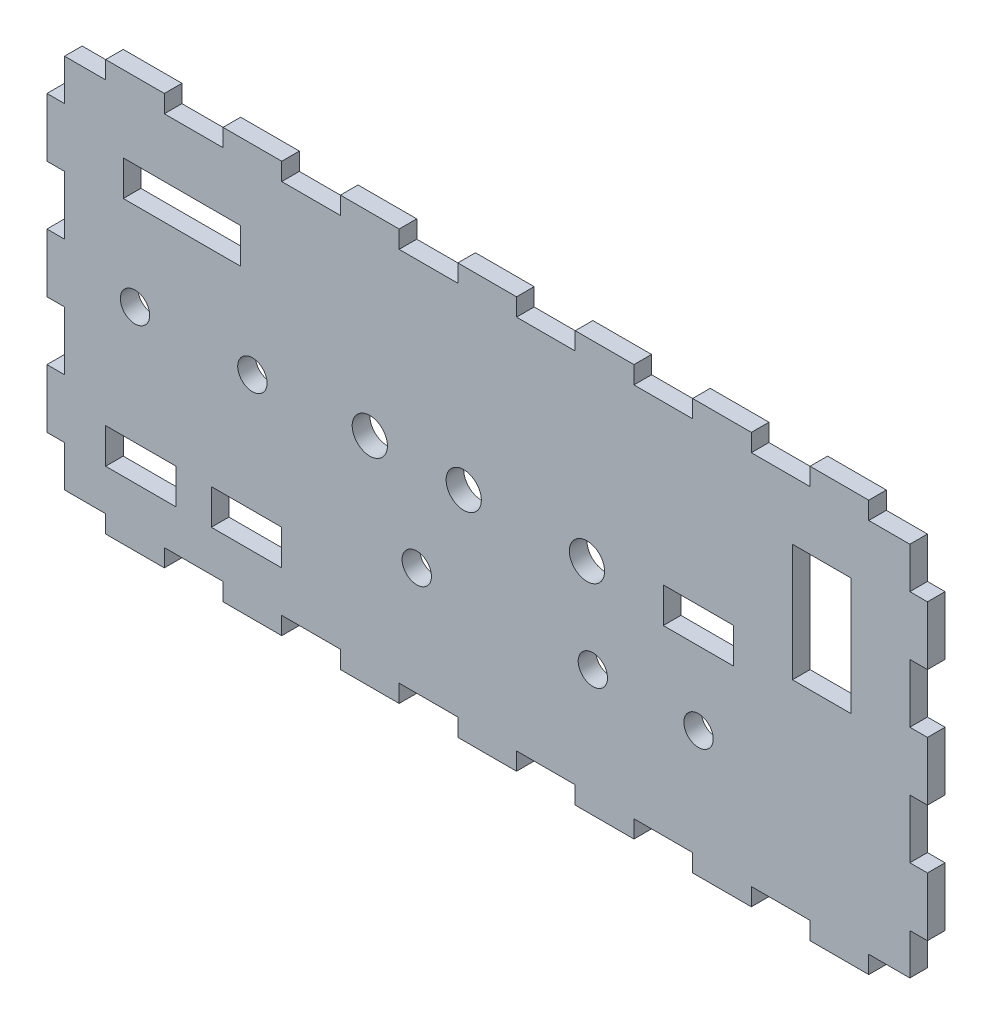
from build123d import *

# Parameters (mm, degrees)
SKETCH1_W               = 150
SKETCH1_H               = 70
BOSS_EXTRUDE1_DEPTH     = 3
SKETCH2_W               = 10
SKETCH2_H               = 3
CUT_EXTRUDE1_DEPTH      = 3
LPATTERN3_COUNT         = 8
LPATTERN3_PITCH         = 20
MIRROR1_COPY_1_SKETCH_W = 10
MIRROR1_COPY_1_SKETCH_H = 3
MIRROR1_COPY_1_DEPTH    = 3
MIRROR1_COPY_2_SKETCH_W = 10
MIRROR1_COPY_2_SKETCH_H = 3
MIRROR1_COPY_2_DEPTH    = 3
MIRROR1_COPY_3_SKETCH_W = 10
MIRROR1_COPY_3_SKETCH_H = 3
MIRROR1_COPY_3_DEPTH    = 3
MIRROR1_COPY_4_SKETCH_W = 10
MIRROR1_COPY_4_SKETCH_H = 3
MIRROR1_COPY_4_DEPTH    = 3
MIRROR1_COPY_5_SKETCH_W = 10
MIRROR1_COPY_5_SKETCH_H = 3
MIRROR1_COPY_5_DEPTH    = 3
MIRROR1_COPY_6_SKETCH_W = 10
MIRROR1_COPY_6_SKETCH_H = 3
MIRROR1_COPY_6_DEPTH    = 3
MIRROR1_COPY_7_SKETCH_W = 10
MIRROR1_COPY_7_SKETCH_H = 3
MIRROR1_COPY_7_DEPTH    = 3
SKETCH3_W               = 3
SKETCH3_H               = 10
CUT_EXTRUDE2_DEPTH      = 3
LPATTERN4_COUNT         = 4
LPATTERN4_PITCH         = 20
MIRROR2_COPY_1_SKETCH_W = 3
MIRROR2_COPY_1_SKETCH_H = 10
MIRROR2_COPY_1_DEPTH    = 3
MIRROR2_COPY_2_SKETCH_W = 3
MIRROR2_COPY_2_SKETCH_H = 10
MIRROR2_COPY_2_DEPTH    = 3
MIRROR2_COPY_3_SKETCH_W = 3
MIRROR2_COPY_3_SKETCH_H = 10
MIRROR2_COPY_3_DEPTH    = 3
SKETCH4_W               = 20
SKETCH4_H               = 6
CUT_EXTRUDE3_DEPTH      = 3
SKETCH5_R               = 2.5
CUT_EXTRUDE5_DEPTH      = 3
SKETCH6_W               = 12
SKETCH6_H               = 6
CUT_EXTRUDE6_DEPTH      = 3
SKETCH7_R               = 3
CUT_EXTRUDE7_DEPTH      = 3
SKETCH8_R               = 2.5
CUT_EXTRUDE8_DEPTH      = 3
SKETCH9_R               = 3
CUT_EXTRUDE9_DEPTH      = 3
SKETCH10_W              = 12
SKETCH10_H              = 6
CUT_EXTRUDE10_DEPTH     = 3
SKETCH11_R              = 2.5
CUT_EXTRUDE11_DEPTH     = 3
SKETCH12_W              = 10
SKETCH12_H              = 20
CUT_EXTRUDE12_DEPTH     = 3


with BuildPart() as part:
    # Sketch1 → Boss-Extrude1 (new body)
    with BuildSketch(Plane.XY):
        Rectangle(SKETCH1_W, SKETCH1_H)
    extrude(amount=BOSS_EXTRUDE1_DEPTH)

    # Sketch2 → Cut-Extrude1 (cut)
    with BuildSketch(Plane.XY.offset(3)):
        with Locations((-70, 33.5)):
            Rectangle(SKETCH2_W, SKETCH2_H)
    cut_extrude1 = extrude(amount=-CUT_EXTRUDE1_DEPTH, mode=Mode.SUBTRACT)

    # LPattern3: Cut-Extrude1 ×8
    with Locations(*[(i * LPATTERN3_PITCH, 0, 0) for i in range(1, LPATTERN3_COUNT)]):
        add(cut_extrude1, mode=Mode.SUBTRACT)

    # Mirror1: Cut-Extrude1 across plane
    add(cut_extrude1.mirror(Plane.ZX), mode=Mode.SUBTRACT)

    # Mirror1 copy 1 sketch → Mirror1 copy 1 (cut)
    with BuildSketch(Plane(origin=(20, 0, 3), x_dir=(1, 0, 0), z_dir=(0, 0, 1))):
        with Locations((-70, -33.5)):
            Rectangle(MIRROR1_COPY_1_SKETCH_W, MIRROR1_COPY_1_SKETCH_H)
    extrude(amount=-MIRROR1_COPY_1_DEPTH, mode=Mode.SUBTRACT)

    # Mirror1 copy 2 sketch → Mirror1 copy 2 (cut)
    with BuildSketch(Plane(origin=(40, 0, 3), x_dir=(1, 0, 0), z_dir=(0, 0, 1))):
        with Locations((-70, -33.5)):
            Rectangle(MIRROR1_COPY_2_SKETCH_W, MIRROR1_COPY_2_SKETCH_H)
    extrude(amount=-MIRROR1_COPY_2_DEPTH, mode=Mode.SUBTRACT)

    # Mirror1 copy 3 sketch → Mirror1 copy 3 (cut)
    with BuildSketch(Plane(origin=(60, 0, 3), x_dir=(1, 0, 0), z_dir=(0, 0, 1))):
        with Locations((-70, -33.5)):
            Rectangle(MIRROR1_COPY_3_SKETCH_W, MIRROR1_COPY_3_SKETCH_H)
    extrude(amount=-MIRROR1_COPY_3_DEPTH, mode=Mode.SUBTRACT)

    # Mirror1 copy 4 sketch → Mirror1 copy 4 (cut)
    with BuildSketch(Plane(origin=(80, 0, 3), x_dir=(1, 0, 0), z_dir=(0, 0, 1))):
        with Locations((-70, -33.5)):
            Rectangle(MIRROR1_COPY_4_SKETCH_W, MIRROR1_COPY_4_SKETCH_H)
    extrude(amount=-MIRROR1_COPY_4_DEPTH, mode=Mode.SUBTRACT)

    # Mirror1 copy 5 sketch → Mirror1 copy 5 (cut)
    with BuildSketch(Plane(origin=(100, 0, 3), x_dir=(1, 0, 0), z_dir=(0, 0, 1))):
        with Locations((-70, -33.5)):
            Rectangle(MIRROR1_COPY_5_SKETCH_W, MIRROR1_COPY_5_SKETCH_H)
    extrude(amount=-MIRROR1_COPY_5_DEPTH, mode=Mode.SUBTRACT)

    # Mirror1 copy 6 sketch → Mirror1 copy 6 (cut)
    with BuildSketch(Plane(origin=(120, 0, 3), x_dir=(1, 0, 0), z_dir=(0, 0, 1))):
        with Locations((-70, -33.5)):
            Rectangle(MIRROR1_COPY_6_SKETCH_W, MIRROR1_COPY_6_SKETCH_H)
    extrude(amount=-MIRROR1_COPY_6_DEPTH, mode=Mode.SUBTRACT)

    # Mirror1 copy 7 sketch → Mirror1 copy 7 (cut)
    with BuildSketch(Plane(origin=(140, 0, 3), x_dir=(1, 0, 0), z_dir=(0, 0, 1))):
        with Locations((-70, -33.5)):
            Rectangle(MIRROR1_COPY_7_SKETCH_W, MIRROR1_COPY_7_SKETCH_H)
    extrude(amount=-MIRROR1_COPY_7_DEPTH, mode=Mode.SUBTRACT)

    # Sketch3 → Cut-Extrude2 (cut)
    with BuildSketch(Plane.XY.offset(3)):
        with Locations((-73.5, 30)):
            Rectangle(SKETCH3_W, SKETCH3_H)
    cut_extrude2 = extrude(amount=-CUT_EXTRUDE2_DEPTH, mode=Mode.SUBTRACT)

    # LPattern4: Cut-Extrude2 ×4
    with Locations(*[(0, -i * LPATTERN4_PITCH, 0) for i in range(1, LPATTERN4_COUNT)]):
        add(cut_extrude2, mode=Mode.SUBTRACT)

    # Mirror2: Cut-Extrude2 across plane
    add(cut_extrude2.mirror(Plane(origin=(0, 0, 0), x_dir=(0, 0, 1), z_dir=(1, 0, 0))), mode=Mode.SUBTRACT)

    # Mirror2 copy 1 sketch → Mirror2 copy 1 (cut)
    with BuildSketch(Plane(origin=(0, -20, 3), x_dir=(-1, 0, 0), z_dir=(0, 0, 1))):
        with Locations((-73.5, -30)):
            Rectangle(MIRROR2_COPY_1_SKETCH_W, MIRROR2_COPY_1_SKETCH_H)
    extrude(amount=-MIRROR2_COPY_1_DEPTH, mode=Mode.SUBTRACT)

    # Mirror2 copy 2 sketch → Mirror2 copy 2 (cut)
    with BuildSketch(Plane(origin=(0, -40, 3), x_dir=(-1, 0, 0), z_dir=(0, 0, 1))):
        with Locations((-73.5, -30)):
            Rectangle(MIRROR2_COPY_2_SKETCH_W, MIRROR2_COPY_2_SKETCH_H)
    extrude(amount=-MIRROR2_COPY_2_DEPTH, mode=Mode.SUBTRACT)

    # Mirror2 copy 3 sketch → Mirror2 copy 3 (cut)
    with BuildSketch(Plane(origin=(0, -60, 3), x_dir=(-1, 0, 0), z_dir=(0, 0, 1))):
        with Locations((-73.5, -30)):
            Rectangle(MIRROR2_COPY_3_SKETCH_W, MIRROR2_COPY_3_SKETCH_H)
    extrude(amount=-MIRROR2_COPY_3_DEPTH, mode=Mode.SUBTRACT)

    # Sketch4 → Cut-Extrude3 (cut)
    with BuildSketch(Plane.XY.offset(3)):
        with Locations((-52, 19)):
            Rectangle(SKETCH4_W, SKETCH4_H)
    extrude(amount=-CUT_EXTRUDE3_DEPTH, mode=Mode.SUBTRACT)

    # Sketch5 → Cut-Extrude5 (cut)
    with BuildSketch(Plane.XY.offset(3)):
        with Locations((-60, 1)):
            Circle(SKETCH5_R)
        with Locations((-40, 1)):
            Circle(SKETCH5_R)
    extrude(amount=-CUT_EXTRUDE5_DEPTH, mode=Mode.SUBTRACT)

    # Sketch6 → Cut-Extrude6 (cut)
    with BuildSketch(Plane.XY.offset(3)):
        with Locations((-59, -22)):
            Rectangle(SKETCH6_W, SKETCH6_H)
        with Locations((-41, -22)):
            Rectangle(SKETCH6_W, SKETCH6_H)
    extrude(amount=-CUT_EXTRUDE6_DEPTH, mode=Mode.SUBTRACT)

    # Sketch7 → Cut-Extrude7 (cut)
    with BuildSketch(Plane.XY.offset(3)):
        with Locations((-20, 2)):
            Circle(SKETCH7_R)
        with Locations((-4, 2)):
            Circle(SKETCH7_R)
    extrude(amount=-CUT_EXTRUDE7_DEPTH, mode=Mode.SUBTRACT)

    # Sketch8 → Cut-Extrude8 (cut)
    with BuildSketch(Plane.XY.offset(3)):
        with Locations((-12, -13.5)):
            Circle(SKETCH8_R)
    extrude(amount=-CUT_EXTRUDE8_DEPTH, mode=Mode.SUBTRACT)

    # Sketch9 → Cut-Extrude9 (cut)
    with BuildSketch(Plane.XY.offset(3)):
        with Locations((17, 2)):
            Circle(SKETCH9_R)
    extrude(amount=-CUT_EXTRUDE9_DEPTH, mode=Mode.SUBTRACT)

    # Sketch10 → Cut-Extrude10 (cut)
    with BuildSketch(Plane.XY.offset(3)):
        with Locations((36, 2)):
            Rectangle(SKETCH10_W, SKETCH10_H)
    extrude(amount=-CUT_EXTRUDE10_DEPTH, mode=Mode.SUBTRACT)

    # Sketch11 → Cut-Extrude11 (cut)
    with BuildSketch(Plane.XY.offset(3)):
        with Locations((18, -13.5)):
            Circle(SKETCH11_R)
        with Locations((36, -13.5)):
            Circle(SKETCH11_R)
    extrude(amount=-CUT_EXTRUDE11_DEPTH, mode=Mode.SUBTRACT)

    # Sketch12 → Cut-Extrude12 (cut)
    with BuildSketch(Plane.XY.offset(3)):
        with Locations((57, 12)):
            Rectangle(SKETCH12_W, SKETCH12_H)
    extrude(amount=-CUT_EXTRUDE12_DEPTH, mode=Mode.SUBTRACT)


solid = part.part
